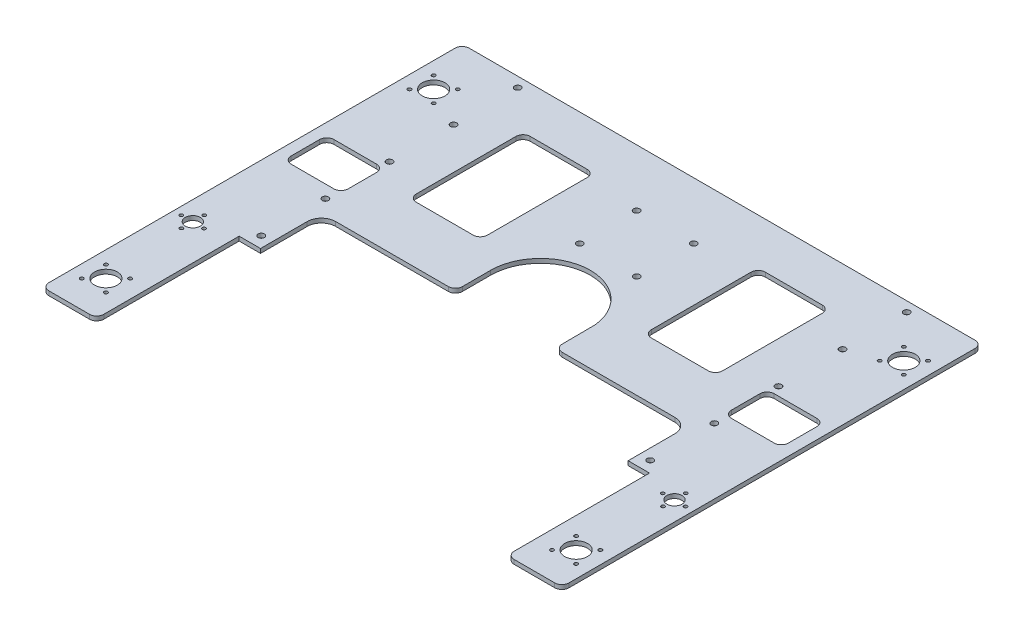
from build123d import *

# Parameters (mm, degrees)
SKETCH1_W           = 365
SKETCH1_H           = 370
BOSS_EXTRUDE1_DEPTH = 3
SKETCH2_W           = 365
SKETCH2_H           = 135
CUT_EXTRUDE1_DEPTH  = 10
SKETCH3_R           = 1.25
SKETCH3_R_2         = 8
CUT_EXTRUDE2_DEPTH  = 10
SKETCH4_R           = 5.3
SKETCH4_R_2         = 1.2
CUT_EXTRUDE3_DEPTH  = 10
SKETCH5_W           = 258
SKETCH5_H           = 82.769773142
CUT_EXTRUDE4_DEPTH  = 10
SKETCH6_W           = 15
SKETCH6_H           = 40
CUT_EXTRUDE5_DEPTH  = 10
CUT_EXTRUDE6_DEPTH  = 10
CUT_EXTRUDE7_DEPTH  = 10
SKETCH9_R           = 2.2
CUT_EXTRUDE8_DEPTH  = 10
FILLET1_R           = 10
CUT_EXTRUDE9_DEPTH  = 10
SKETCH11_R          = 2.2
CUT_EXTRUDE10_DEPTH = 10
SKETCH12_W          = 38.5
SKETCH12_H          = 60
BOSS_EXTRUDE2_DEPTH = 3
LPATTERN1_COUNT     = 2
LPATTERN1_PITCH     = 230
FILLET2_R           = 5


with BuildPart() as part:
    # Sketch1 → Boss-Extrude1 (new body)
    with BuildSketch(Plane(origin=(0, 0, 0), x_dir=(1, 0, 0), z_dir=(0, 1, 0))):
        Rectangle(SKETCH1_W, SKETCH1_H)
    extrude(amount=BOSS_EXTRUDE1_DEPTH)

    # Sketch2 → Cut-Extrude1 (cut)
    with BuildSketch(Plane(origin=(0, 3, 0), x_dir=(1, 0, 0), z_dir=(0, 1, 0))):
        with Locations((0, -117.5)):
            Rectangle(SKETCH2_W, SKETCH2_H)
    extrude(amount=-CUT_EXTRUDE1_DEPTH, mode=Mode.SUBTRACT)

    # Sketch3 → Cut-Extrude2 (cut)
    with BuildSketch(Plane(origin=(0, 3, 0), x_dir=(1, 0, 0), z_dir=(0, 1, 0))):
        with Locations((-173.485281374, 155.985281374)):
            Circle(SKETCH3_R)
        with Locations((-173.485281374, 139.014718626)):
            Circle(SKETCH3_R)
        with Locations((-156.514718626, 155.985281374)):
            Circle(SKETCH3_R)
        with Locations((-156.514718626, 139.014718626)):
            Circle(SKETCH3_R)
        with Locations((-165, 147.5)):
            Circle(SKETCH3_R_2)
        with Locations((156.514718626, 155.985281374)):
            Circle(SKETCH3_R)
        with Locations((173.485281374, 155.985281374)):
            Circle(SKETCH3_R)
        with Locations((173.485281374, 139.014718626)):
            Circle(SKETCH3_R)
        with Locations((156.514718626, 139.014718626)):
            Circle(SKETCH3_R)
        with Locations((165, 147.5)):
            Circle(SKETCH3_R_2)
    cut_extrude2 = extrude(amount=-CUT_EXTRUDE2_DEPTH, mode=Mode.SUBTRACT)

    # Sketch4 → Cut-Extrude3 (cut)
    with BuildSketch(Plane(origin=(0, 3, 0), x_dir=(1, 0, 0), z_dir=(0, 1, 0))):
        with Locations((-169, -17.5)):
            Circle(SKETCH4_R)
        with Locations((-169, -9.5)):
            Circle(SKETCH4_R_2)
        with Locations((-169, -25.5)):
            Circle(SKETCH4_R_2)
        with Locations((-161, -17.674075017)):
            Circle(SKETCH4_R_2)
        with Locations((-177, -17.674075017)):
            Circle(SKETCH4_R_2)
    cut_extrude3 = extrude(amount=-CUT_EXTRUDE3_DEPTH, mode=Mode.SUBTRACT)

    # Mirror1: Cut-Extrude3 across plane
    add(cut_extrude3.mirror(Plane(origin=(0, 0, 0), x_dir=(0, 0, 1), z_dir=(1, 0, 0))), mode=Mode.SUBTRACT)

    # Sketch5 → Cut-Extrude4 (cut)
    with BuildSketch(Plane(origin=(0, 3, 0), x_dir=(1, 0, 0), z_dir=(0, 1, 0))):
        with Locations((0, -8.615113429)):
            Rectangle(SKETCH5_W, SKETCH5_H)
    extrude(amount=-CUT_EXTRUDE4_DEPTH, mode=Mode.SUBTRACT)

    # Sketch6 → Cut-Extrude5 (cut)
    with BuildSketch(Plane(origin=(0, 3, 0), x_dir=(1, 0, 0), z_dir=(0, 1, 0))):
        with Locations((-136.5, -30)):
            Rectangle(SKETCH6_W, SKETCH6_H)
    cut_extrude5 = extrude(amount=-CUT_EXTRUDE5_DEPTH, mode=Mode.SUBTRACT)

    # Mirror2: Cut-Extrude5 across plane
    add(cut_extrude5.mirror(Plane(origin=(0, 0, 0), x_dir=(0, 0, 1), z_dir=(1, 0, 0))), mode=Mode.SUBTRACT)

    # Sketch7 → Cut-Extrude6 (cut)
    with BuildSketch(Plane(origin=(0, 3, 0), x_dir=(1, 0, 0), z_dir=(0, 1, 0))):
        with BuildLine():
            ThreePointArc((-24.767233991, 32.769773142), (-32.340788408, 44.118168841), (-35, 57.5))
            Line((-35, 57.5), (-35, 32.769773142))
            Line((-35, 32.769773142), (-24.767233991, 32.769773142))
        make_face()
        with BuildLine():
            ThreePointArc((34.808648008, 61.154863037), (-1.829934385, 92.452129265), (-35, 57.5))
            ThreePointArc((-35, 57.5), (-32.340788408, 44.118168841), (-24.767233991, 32.769773142))
            Line((-24.767233991, 32.769773142), (24.767233991, 32.769773142))
            ThreePointArc((24.767233991, 32.769773142), (31.697667218, 42.658912002), (34.854759109, 54.31475787))
            Line((34.854759109, 54.31475787), (34.808648008, 61.154863037))
        make_face()
        with BuildLine():
            Line((35, 32.769773142), (34.854759109, 54.31475787))
            ThreePointArc((34.854759109, 54.31475787), (31.697667218, 42.658912002), (24.767233991, 32.769773142))
            Line((24.767233991, 32.769773142), (35, 32.769773142))
        make_face()
    extrude(amount=-CUT_EXTRUDE6_DEPTH, mode=Mode.SUBTRACT)

    # Sketch8 → Cut-Extrude7 (cut)
    with BuildSketch(Plane(origin=(0, 3, 0), x_dir=(1, 0, 0), z_dir=(0, 1, 0))):
        with BuildLine():
            Line((-169.5, 52), (-139.5, 52))
            ThreePointArc((-139.5, 52), (-135.964466094, 53.464466094), (-134.5, 57))
            Line((-134.5, 57), (-134.5, 77))
            ThreePointArc((-134.5, 77), (-135.964466094, 80.535533906), (-139.5, 82))
            Line((-139.5, 82), (-169.5, 82))
            ThreePointArc((-169.5, 82), (-173.035533906, 80.535533906), (-174.5, 77))
            Line((-174.5, 77), (-174.5, 57))
            ThreePointArc((-174.5, 57), (-173.035533906, 53.464466094), (-169.5, 52))
        make_face()
    cut_extrude7 = extrude(amount=-CUT_EXTRUDE7_DEPTH, mode=Mode.SUBTRACT)

    # Mirror3: Cut-Extrude7 across plane
    add(cut_extrude7.mirror(Plane(origin=(0, 0, 0), x_dir=(0, 0, 1), z_dir=(1, 0, 0))), mode=Mode.SUBTRACT)

    # Sketch9 → Cut-Extrude8 (cut)
    with BuildSketch(Plane(origin=(0, 3, 0), x_dir=(1, 0, 0), z_dir=(0, 1, 0))):
        with Locations((-136.5, -2)):
            Circle(SKETCH9_R)
        with Locations((-136.5, 43)):
            Circle(SKETCH9_R)
        with Locations((-136.5, 88)):
            Circle(SKETCH9_R)
        with Locations((-136.5, 133)):
            Circle(SKETCH9_R)
        with Locations((-136.5, 178)):
            Circle(SKETCH9_R)
        with Locations((136.5, 178)):
            Circle(SKETCH9_R)
        with Locations((136.5, 133)):
            Circle(SKETCH9_R)
        with Locations((136.5, 88)):
            Circle(SKETCH9_R)
        with Locations((136.5, 43)):
            Circle(SKETCH9_R)
        with Locations((136.5, -2)):
            Circle(SKETCH9_R)
    extrude(amount=-CUT_EXTRUDE8_DEPTH, mode=Mode.SUBTRACT)

    # Fillet1
    fillet1_edges = [part.edges().sort_by_distance(p)[0] for p in [
        (-129, 1.5, -32.769773142),
        (129, 1.5, -32.769773142),
    ]]
    fillet(fillet1_edges, radius=FILLET1_R)

    # Sketch10 → Cut-Extrude9 (cut)
    with BuildSketch(Plane(origin=(0, 3, 0), x_dir=(1, 0, 0), z_dir=(0, 1, 0))):
        with BuildLine():
            Line((102.5, 72.769773142), (62.5, 72.769773142))
            ThreePointArc((62.5, 72.769773142), (58.964466094, 74.234239236), (57.5, 77.769773142))
            Line((57.5, 77.769773142), (57.5, 147.769773142))
            ThreePointArc((57.5, 147.769773142), (58.964466094, 151.305307048), (62.5, 152.769773142))
            Line((62.5, 152.769773142), (102.5, 152.769773142))
            ThreePointArc((102.5, 152.769773142), (106.035533906, 151.305307048), (107.5, 147.769773142))
            Line((107.5, 147.769773142), (107.5, 77.769773142))
            ThreePointArc((107.5, 77.769773142), (106.035533906, 74.234239236), (102.5, 72.769773142))
        make_face()
        with BuildLine():
            Line((-57.5, 77.769773142), (-57.5, 147.769773142))
            ThreePointArc((-57.5, 147.769773142), (-58.964466094, 151.305307048), (-62.5, 152.769773142))
            Line((-62.5, 152.769773142), (-102.5, 152.769773142))
            ThreePointArc((-102.5, 152.769773142), (-106.035533906, 151.305307048), (-107.5, 147.769773142))
            Line((-107.5, 147.769773142), (-107.5, 77.769773142))
            ThreePointArc((-107.5, 77.769773142), (-106.035533906, 74.234239236), (-102.5, 72.769773142))
            Line((-102.5, 72.769773142), (-62.5, 72.769773142))
            ThreePointArc((-62.5, 72.769773142), (-58.964466094, 74.234239236), (-57.5, 77.769773142))
        make_face()
    extrude(amount=-CUT_EXTRUDE9_DEPTH, mode=Mode.SUBTRACT)

    # Sketch11 → Cut-Extrude10 (cut)
    with BuildSketch(Plane(origin=(0, 3, 0), x_dir=(1, 0, 0), z_dir=(0, 1, 0))):
        with Locations((20, 145)):
            Circle(SKETCH11_R)
        with Locations((20, 105)):
            Circle(SKETCH11_R)
        with Locations((-20, 105)):
            Circle(SKETCH11_R)
        with Locations((-20, 145)):
            Circle(SKETCH11_R)
    extrude(amount=-CUT_EXTRUDE10_DEPTH, mode=Mode.SUBTRACT)

    # Sketch12 → Boss-Extrude2 (add)
    with BuildSketch(Plane(origin=(0, 3, 0), x_dir=(1, 0, 0), z_dir=(0, 1, 0))):
        with Locations((-163.25, -80)):
            Rectangle(SKETCH12_W, SKETCH12_H)
    boss_extrude2 = extrude(amount=-BOSS_EXTRUDE2_DEPTH)

    # Mirror4: Boss-Extrude2 across plane
    add(boss_extrude2.mirror(Plane(origin=(0, 0, 0), x_dir=(0, 0, 1), z_dir=(1, 0, 0))))

    # LPattern1: Cut-Extrude2 ×2
    with Locations(*[(0, 0, i * LPATTERN1_PITCH) for i in range(1, LPATTERN1_COUNT)]):
        add(cut_extrude2, mode=Mode.SUBTRACT)

    # Fillet2
    fillet2_edges = [part.edges().sort_by_distance(p)[0] for p in [
        (35, 1.5, -32.769773142),
        (-35, 1.5, -32.769773142),
        (-182.5, 1.5, 110),
        (-144, 1.5, 110),
        (182.5, 1.5, 110),
        (144, 1.5, 110),
        (-182.5, 1.5, -185),
        (182.5, 1.5, -185),
    ]]
    fillet(fillet2_edges, radius=FILLET2_R)


solid = part.part
